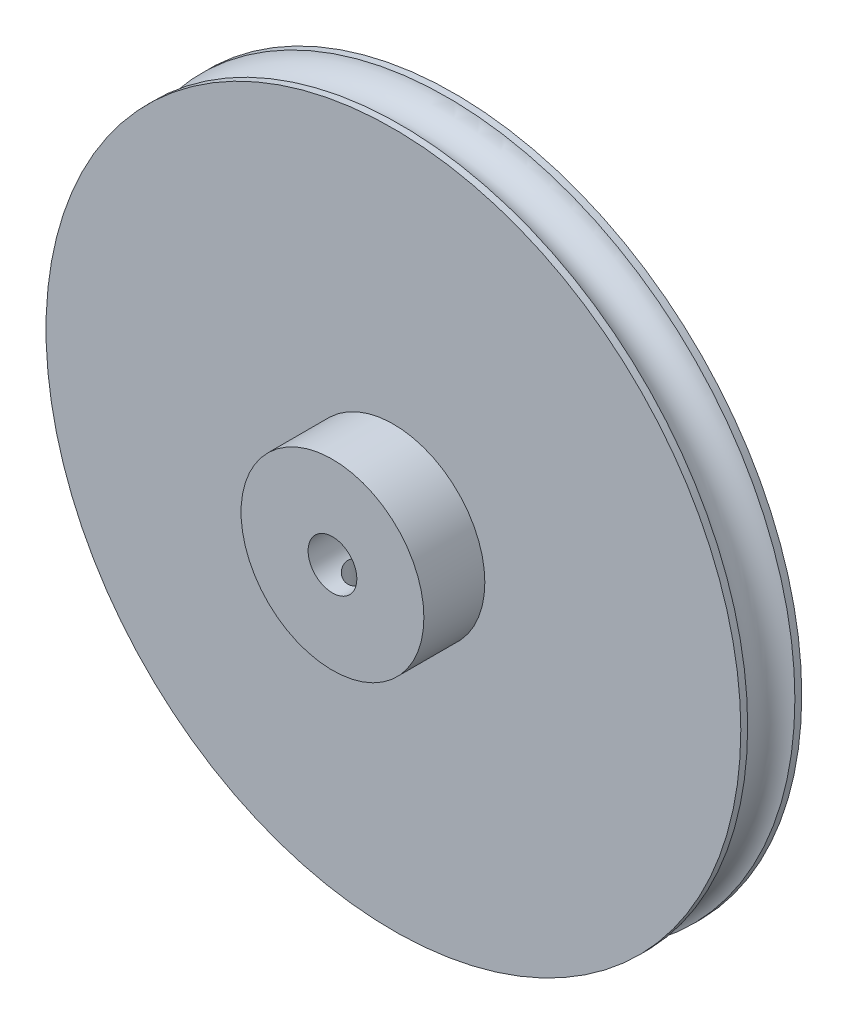
from build123d import *

# Parameters (mm, degrees)
ESQUISSE1_R      = 28.5
EXTRUSION1_DEPTH = 5
ESQUISSE2_R      = 7.5
EXTRUSION2_DEPTH = 5
EXTRUSION3_REACH = 12
ESQUISSE3_R      = 2
ESQUISSE12_W     = 1.25
ESQUISSE12_H     = 28.5


with BuildPart() as part:
    # Esquisse1 → Extrusion1 (new body)
    with BuildSketch(Plane.XY):
        Circle(ESQUISSE1_R)
    extrude(amount=-EXTRUSION1_DEPTH)

    # Esquisse2 → Extrusion2 (add)
    with BuildSketch(Plane.XY):
        Circle(ESQUISSE2_R)
    extrude(amount=EXTRUSION2_DEPTH)

    # Esquisse3 → Extrusion3 (cut, up to next)
    with BuildSketch(Plane.XY.offset(5), mode=Mode.PRIVATE) as extrusion3_sk1:
        Circle(ESQUISSE3_R)
    extrusion3_tool1 = extrude(extrusion3_sk1.sketch, amount=-EXTRUSION3_REACH, mode=Mode.PRIVATE) & part.part
    add(extrusion3_tool1.solids().sort_by_distance((0, 0, 5))[0], mode=Mode.SUBTRACT)

    # Esquisse6 → Enlèvement de matière-Révolution3 (revolve, cut)
    with BuildSketch(Plane(origin=(0, 0, 0), x_dir=(1, 0, 0), z_dir=(0, 1, 0))):
        with BuildLine():
            Line((-29, 4.5), (-31.449617094, 4.5))
            Line((-31.449617094, 4.5), (-31.449617094, 0.5))
            Line((-31.449617094, 0.5), (-29, 0.5))
            ThreePointArc((-29, 0.5), (-27, 2.5), (-29, 4.5))
        make_face()
    revolve(axis=Axis((0, 0, 5), (0, 0, -1)), mode=Mode.SUBTRACT)

    # Esquisse12 → Trou taraudé M3x0.55 (revolve, cut)
    with BuildSketch(Plane(origin=(0, 0, 2.5), x_dir=(0, 0, 1), z_dir=(1, 0, 0))):
        with Locations((0.625, 14.25)):
            Rectangle(ESQUISSE12_W, ESQUISSE12_H)
    revolve(axis=Axis((0, 6.35, 2.5), (0, -1, 0)), mode=Mode.SUBTRACT)


solid = part.part
